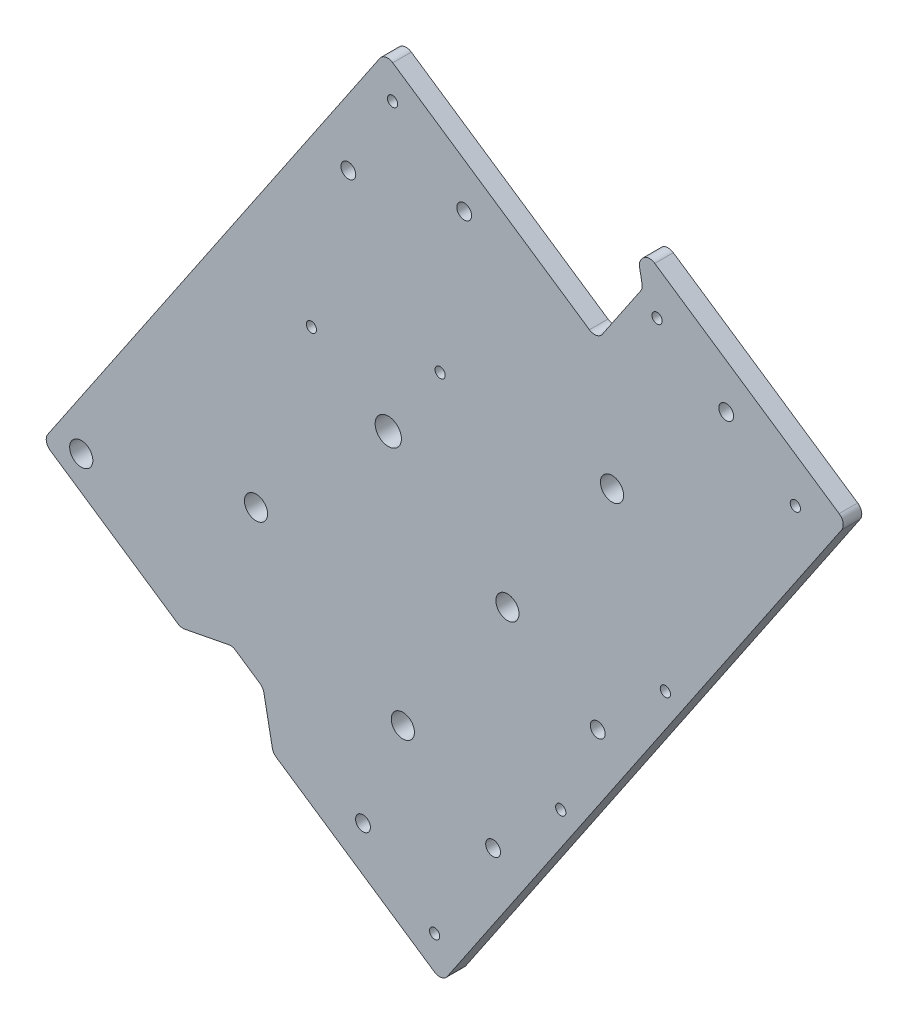
from build123d import *

# Parameters (mm, degrees)
BOSS_EXTRUDE2_DEPTH = 6.35
CUT_EXTRUDE1_DEPTH  = 7.3500001
BOSS_EXTRUDE3_DEPTH = 6.35
SKETCH10_R          = 3.96875
CUT_EXTRUDE2_DEPTH  = 7.35
SKETCH11_R          = 4.5
CUT_EXTRUDE4_DEPTH  = 7.35
BOSS_EXTRUDE4_DEPTH = 6.35
SKETCH13_R          = 1.75
CUT_EXTRUDE5_DEPTH  = 7.35
LPATTERN1_COUNT     = 2
LPATTERN1_PITCH     = 64
SKETCH14_R          = 2.54
CUT_EXTRUDE6_DEPTH  = 7.35
SKETCH15_R          = 1.75
CUT_EXTRUDE7_DEPTH  = 7.35
SKETCH16_R          = 1.75
CUT_EXTRUDE8_DEPTH  = 7.35
SKETCH17_R          = 1.75
CUT_EXTRUDE9_DEPTH  = 7.35
SKETCH19_R          = 3.96875
CUT_EXTRUDE11_DEPTH = 7.35
SKETCH21_R          = 2.54
CUT_EXTRUDE12_DEPTH = 7.35
SKETCH22_R          = 3.96875
CUT_EXTRUDE13_DEPTH = 7.35
SKETCH23_R          = 4.885116726
SKETCH23_R_2        = 5.670398183
BOSS_EXTRUDE5_DEPTH = 6.35
CUT_EXTRUDE14_DEPTH = 7.35
FILLET1_R           = 3.175


with BuildPart() as part:
    # Sketch6 → Boss-Extrude2 (new body)
    with BuildSketch(Plane.XY):
        with BuildLine():
            Line((-68.006850091, -76.67090114), (-109.486767671, -48.656527855))
            Line((-109.486767671, -48.656527855), (-118.371760678, -61.812230963))
            Line((-118.371760678, -61.812230963), (18.447551645, -154.216158235))
            Line((18.447551645, -154.216158235), (135.729459338, 19.43912279))
            Line((135.729459338, 19.43912279), (-1.089852986, 111.843050063))
            Line((-1.089852986, 111.843050063), (-73.946795643, 3.966284577))
            Line((-73.946795643, 3.966284577), (-56.624438948, -7.732749433))
            ThreePointArc((-56.624438948, -7.732749433), (-43.058385537, 37.577891571), (0, 57.15))
            ThreePointArc((0, 57.15), (56.404848571, 31.095576642), (70.829334649, -29.338471048))
            add(Edge.make_bspline(
                [(70.829334649, -29.338471048), (70.811686062, -29.418295928), (70.776015112, -29.578104383), (70.713320217, -29.85478305), (70.619021771, -30.262929245), (70.501052001, -30.762086912), (70.364034474, -31.322191481), (70.199318515, -31.970958926), (70.000453855, -32.723919765), (69.795103485, -33.469783355), (69.582015398, -34.214296028), (69.361377803, -34.956693289), (69.133257682, -35.696762218), (68.838782679, -36.61892651), (68.470566207, -37.720710028), (68.019498024, -38.998776477), (67.474836154, -40.448808619), (66.901337925, -41.887676852), (66.299328392, -43.31485223), (65.669141732, -44.729810424), (65.011119088, -46.132040323), (64.325609411, -47.52103904), (63.612968547, -48.896314904), (62.87355937, -50.257385735), (62.107751613, -51.603779381), (61.315921169, -52.935034173), (60.49845004, -54.250698756), (59.655726138, -55.550331897), (58.571247582, -57.154294757), (57.220953058, -59.045283389), (55.576035723, -61.200397094), (53.604026134, -63.590264702), (51.54329346, -65.904053004), (49.39728314, -68.138962994), (47.169496434, -70.29235602), (44.863486103, -72.361752995), (42.482847363, -74.344831806), (40.031215607, -76.239428526), (36.882516177, -78.494556171), (32.976808929, -81.016011003), (28.250788286, -83.68089187), (21.41551215, -86.919136497), (14.30829026, -89.526654921), (6.996956895, -91.488176442), (-0.451922312, -92.797413176), (-6.61686174, -93.456358442), (-12.81195397, -93.702029749), (-19.009644204, -93.537285056), (-25.183124422, -92.966685286), (-31.306438312, -91.996382122), (-36.598524037, -90.804323442), (-41.072542301, -89.543185606), (-44.752319298, -88.33589156), (-47.664184976, -87.27761875), (-50.541347258, -86.128353728), (-53.381128552, -84.889612663), (-56.180924218, -83.562977818), (-58.593536599, -82.326710176), (-60.633378351, -81.214215821), (-62.313751085, -80.252471782), (-63.646071553, -79.462491566), (-64.966093336, -78.652178853), (-66.222359154, -77.854259082), (-67.143044791, -77.250601571), (-67.736251212, -76.85365602), (-68.006850091, -76.67090114)],
                knots=[0.071020771, 0.071020771, 0.071020771, 0.071020771, 0.071020771, 0.072848477, 0.074676184, 0.07650389, 0.078331597, 0.08198701, 0.085642423, 0.089297836, 0.092953249, 0.096608662, 0.100264075, 0.103919488, 0.107574901, 0.114885727, 0.122196554, 0.12950738, 0.136818214, 0.144129048, 0.151439882, 0.158750716, 0.166061558, 0.173372401, 0.180683243, 0.187994085, 0.195304924, 0.202615763, 0.209926602, 0.217237441, 0.231859103, 0.246480766, 0.261102426, 0.275724085, 0.290345754, 0.304967424, 0.319589099, 0.334210774, 0.348832457, 0.36345414, 0.392697464, 0.421940789, 0.451184112, 0.506140643, 0.535383973, 0.564627303, 0.593870641, 0.623113979, 0.652357319, 0.68160066, 0.710843985, 0.740087309, 0.754708984, 0.769330659, 0.783952333, 0.798574008, 0.813195669, 0.82781733, 0.842438991, 0.849749821, 0.857060652, 0.86437149, 0.871682327, 0.878993165, 0.885158103, 0.885158103, 0.885158103, 0.885158103, 0.885158103], degree=4))
        make_face()
    extrude(amount=BOSS_EXTRUDE2_DEPTH)

    # Sketch8 → Cut-Extrude1 (cut, through all)
    with BuildSketch(Plane.XY.offset(6.35)):
        Polygon((-71.011229489, -93.798205788), (-53.378672597, -90.381637707), (-42.854110111, -97.489632113), (-39.43754203, -115.122189004), align=None)
    extrude(amount=-CUT_EXTRUDE1_DEPTH, mode=Mode.SUBTRACT)

    # Sketch9 → Boss-Extrude3 (add, through all)
    with BuildSketch(Plane.XY.offset(6.35)):
        Polygon((-1.089852986, 111.843050063), (-109.486767671, -48.656527855), (27.332544652, -141.060455127), (135.729459338, 19.43912279), align=None)
    extrude(amount=-BOSS_EXTRUDE3_DEPTH)

    # Sketch10 → Cut-Extrude2 (cut, through all)
    with BuildSketch(Plane.XY.offset(6.35)):
        with Locations((4.996496209, -84.796642912)):
            Circle(SKETCH10_R)
        with Locations((40.816310536, -31.759477627)):
            Circle(SKETCH10_R)
        with Locations((76.636124864, 21.277687659)):
            Circle(SKETCH10_R)
        with Locations((-45.295165913, -45.214466102)):
            Circle(SKETCH10_R)
    extrude(amount=-CUT_EXTRUDE2_DEPTH, mode=Mode.SUBTRACT)

    # Sketch11 → Cut-Extrude4 (cut, through all)
    with BuildSketch(Plane.XY.offset(6.35)):
        Circle(SKETCH11_R)
    extrude(amount=-CUT_EXTRUDE4_DEPTH, mode=Mode.SUBTRACT)

    # Sketch12 → Boss-Extrude4 (add, through all)
    with BuildSketch(Plane.XY.offset(6.35)):
        Polygon((135.729459338, 19.43912279), (67.319803176, 65.641086427), (88.643786393, 97.214773886), (157.053442554, 51.01281025), align=None)
    extrude(amount=-BOSS_EXTRUDE4_DEPTH)

    # Sketch13 → Cut-Extrude5 (cut, through all)
    with BuildSketch(Plane.XY.offset(6.35)):
        with Locations((94.899221836, -29.671127724)):
            Circle(SKETCH13_R)
    cut_extrude5 = extrude(amount=-CUT_EXTRUDE5_DEPTH, mode=Mode.SUBTRACT)

    # LPattern1: Cut-Extrude5 ×2
    with Locations(*[Vector(-0.559684599, -0.828705708, 0) * (i * LPATTERN1_PITCH) for i in range(1, LPATTERN1_COUNT)]):
        add(cut_extrude5, mode=Mode.SUBTRACT)

    # Sketch14 → Cut-Extrude6 (cut, through all)
    with BuildSketch(Plane.XY.offset(6.35)):
        with Locations((71.72703343, -52.635713164)):
            Circle(SKETCH14_R)
        with Locations((35.907219102, -105.67287845)):
            Circle(SKETCH14_R)
        with Locations((115.740620068, 63.589229581)):
            Circle(SKETCH14_R)
    extrude(amount=-CUT_EXTRUDE6_DEPTH, mode=Mode.SUBTRACT)

    # Sketch15 → Cut-Extrude7 (cut, through all)
    with BuildSketch(Plane.XY.offset(6.35)):
        with Locations((-105.147343009, -59.249804902)):
            Circle(SKETCH15_R)
        with Locations((15.885125585, -140.991740566)):
            Circle(SKETCH15_R)
        with Locations((1.472573075, 98.618632394)):
            Circle(SKETCH15_R)
    extrude(amount=-CUT_EXTRUDE7_DEPTH, mode=Mode.SUBTRACT)

    # Sketch16 → Cut-Extrude8 (cut, through all)
    with BuildSketch(Plane.XY.offset(6.35)):
        with Locations((92.060354474, 79.582216994)):
            Circle(SKETCH16_R)
        with Locations((139.420885662, 47.596242169)):
            Circle(SKETCH16_R)
    extrude(amount=-CUT_EXTRUDE8_DEPTH, mode=Mode.SUBTRACT)

    # Sketch17 → Cut-Extrude9 (cut, through all)
    with BuildSketch(Plane.XY.offset(6.35)):
        with Locations((-26.311406216, 17.769986014)):
            Circle(SKETCH17_R)
        with Locations((17.769986014, 26.311406216)):
            Circle(SKETCH17_R)
    extrude(amount=-CUT_EXTRUDE9_DEPTH, mode=Mode.SUBTRACT)

    # Sketch19 → Cut-Extrude11 (cut, through all)
    with BuildSketch(Plane.XY.offset(6.35)):
        with Locations((-65.680233685, -85.904783923)):
            Circle(SKETCH19_R)
    extrude(amount=-CUT_EXTRUDE11_DEPTH, mode=Mode.SUBTRACT)

    # Sketch21 → Cut-Extrude12 (cut, through all)
    with BuildSketch(Plane.XY.offset(6.35)):
        with Locations((-13.666272317, 70.530227577)):
            Circle(SKETCH21_R)
        with Locations((26.00698069, 78.217505758)):
            Circle(SKETCH21_R)
        with Locations((-86.729358658, -71.688795112)):
            Circle(SKETCH21_R)
        with Locations((-8.64928203, -120.590613931)):
            Circle(SKETCH21_R)
    extrude(amount=-CUT_EXTRUDE12_DEPTH, mode=Mode.SUBTRACT)

    # Sketch22 → Cut-Extrude13 (cut, through all)
    with BuildSketch(Plane.XY.offset(6.35)):
        with Locations((-105.147343009, -59.249804902)):
            Circle(SKETCH22_R)
    extrude(amount=-CUT_EXTRUDE13_DEPTH, mode=Mode.SUBTRACT)

    # Sketch23 → Boss-Extrude5 (add, through all)
    with BuildSketch(Plane.XY.offset(6.35)):
        with Locations((-86.729358658, -71.688795112)):
            Circle(SKETCH23_R)
        with Locations((-65.680233685, -85.904783923)):
            Circle(SKETCH23_R_2)
    extrude(amount=-BOSS_EXTRUDE5_DEPTH)

    # Sketch24 → Cut-Extrude14 (cut, through all)
    with BuildSketch(Plane.XY.offset(6.35)):
        Polygon((85.800588631, 93.004948891), (87.167215863, 85.951926135), (71.529628171, 62.797888664), (67.319803176, 65.641086427), align=None)
    extrude(amount=-CUT_EXTRUDE14_DEPTH, mode=Mode.SUBTRACT)

    # Fillet1
    fillet1_edges = [part.edges().sort_by_distance(p)[0] for p in [
        (-1.089852986, 111.843050063, 3.175),
        (18.447551645, -154.216158235, 3.175),
        (-118.371760678, -61.812230963, 3.175),
        (85.800588631, 93.004948891, 3.175),
        (87.167215863, 85.951926135, 3.175),
        (71.529628171, 62.797888664, 3.175),
        (-39.43754203, -115.122189004, 3.175),
        (-71.011229489, -93.798205788, 3.175),
        (-53.378672597, -90.381637707, 3.175),
        (-42.854110111, -97.489632113, 3.175),
        (157.053442554, 51.01281025, 3.175),
        (88.643786393, 97.214773886, 3.175),
    ]]
    fillet(fillet1_edges, radius=FILLET1_R)


solid = part.part
